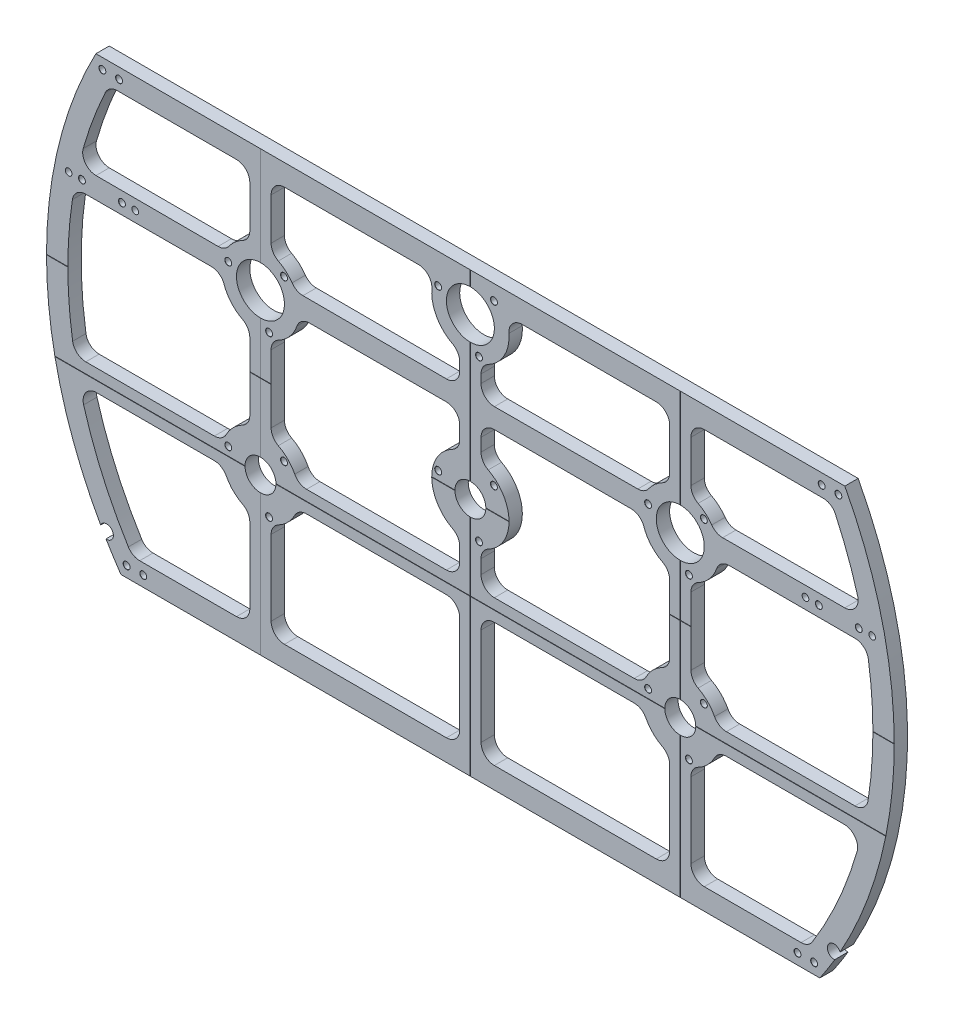
from build123d import *

# Parameters (mm, degrees)
BOSS_EXTRUDE1_DEPTH               = 12.7
SKETCH2_R                         = 3.175
CUT_EXTRUDE2_DEPTH                = 572.285470846
SKETCH5_R                         = 14.732
SKETCH5_R_2                       = 22.86
CUT_EXTRUDE3_DEPTH                = 572.285470846
CUT_EXTRUDE1_DEPTH                = 465.243631728
CIRPATTERN1_COUNT                 = 2
CIRPATTERN1_ANGLE                 = 90
F_1_4_20_TAPPED_HOLE1_D           = 6.35
F_1_4_20_TAPPED_HOLE1_CSINK_D     = 6.604
F_1_4_20_TAPPED_HOLE1_CSINK_ANGLE = 90
CUT_EXTRUDE4_DEPTH                = 465.243631728
CUT_EXTRUDE4_DEPTH_BACK           = 465.243631728
CUT_EXTRUDE5_DEPTH                = 465.243631728
CUT_EXTRUDE5_DEPTH_BACK           = 465.243631728
CUT_EXTRUDE6_DEPTH                = 465.243631728
FILLET1_R                         = 12.7


with BuildPart() as part:
    # Sketch → Boss-Extrude1 (new body)
    with BuildSketch(Plane.XY):
        with BuildLine():
            ThreePointArc((352.277102438, -197.493652299), (0, 403.86), (-352.277102438, -197.493652299))
            ThreePointArc((-352.277102438, -197.493652299), (-340.95420147, -196.85), (-347.173071195, -206.334093733))
            ThreePointArc((-347.173071195, -206.334093733), (0, -403.86), (347.173071195, -206.334093733))
            ThreePointArc((347.173071195, -206.334093733), (340.95420147, -196.85), (352.277102438, -197.493652299))
        make_face()
    extrude(amount=-BOSS_EXTRUDE1_DEPTH)

    # Sketch2 → Cut-Extrude2 (cut, through all)
    with BuildSketch(Plane.XY):
        with Locations((319.291621474, 78.613)):
            Circle(SKETCH2_R)
        with Locations((382.791621474, 78.613)):
            Circle(SKETCH2_R)
        with Locations(Location((-382.791621474, 78.613, 0), (0, 0, 180))):
            Circle(SKETCH2_R)
        with Locations(Location((-319.291621474, 78.613, 0), (0, 0, 180))):
            Circle(SKETCH2_R)
    extrude(amount=-CUT_EXTRUDE2_DEPTH, mode=Mode.SUBTRACT)

    # Sketch5 → Cut-Extrude3 (cut, through all)
    with BuildSketch(Plane(origin=(0, 0, -12.7), x_dir=(-1, 0, 0), z_dir=(0, 0, -1))):
        with Locations((-200, -80)):
            Circle(SKETCH5_R)
        with Locations((200, -80)):
            Circle(SKETCH5_R)
        with Locations((0, 152.4)):
            Circle(SKETCH5_R_2)
        Circle(SKETCH5_R)
        with Locations((-200, 72.4)):
            Circle(SKETCH5_R_2)
        with Locations((200, 72.4)):
            Circle(SKETCH5_R_2)
        with BuildLine():
            Line((356.78411778, 189.23), (-356.78411778, 189.23))
            ThreePointArc((-356.78411778, 189.23), (0, 403.86), (356.78411778, 189.23))
        make_face()
        with BuildLine():
            Line((332.93383667, -228.6), (-332.93383667, -228.6))
            ThreePointArc((-332.93383667, -228.6), (0, -403.86), (332.93383667, -228.6))
        make_face()
    extrude(amount=-CUT_EXTRUDE3_DEPTH, mode=Mode.SUBTRACT)

    # Sketch1 → Cut-Extrude1 (cut, symmetric)
    with BuildSketch(Plane(origin=(0, 0, 0), x_dir=(1, 0, 0), z_dir=(0, 1, 0))):
        Polygon((0.1905, 0), (-0.1905, 0), (0, 0.1905), align=None)
    cut_extrude1 = extrude(amount=CUT_EXTRUDE1_DEPTH, both=True, mode=Mode.SUBTRACT)

    # CirPattern1: Cut-Extrude1 ×2 about axis
    cirpattern1_axis = Axis((0, 0, -13.335), (0, 0, 1))
    for i in range(1, CIRPATTERN1_COUNT):
        add(cut_extrude1.rotate(cirpattern1_axis, i * CIRPATTERN1_ANGLE / (CIRPATTERN1_COUNT - 1)), mode=Mode.SUBTRACT)

    # 1_4-20 Tapped Hole1 (through all)
    with Locations(Plane.XY):
        with Locations((331.991621474, 78.613), (370.091621474, 78.613), (-370.091621474, 78.613), (-331.991621474, 78.613), (327.54183916, -218.44), (-327.54183916, -218.44), (350.618917202, 179.07), (222.450640303, 94.850640303), (-177.549359697, 94.850640303), (-191.782495318, 41.731855015), (-230.668144985, 80.617504682), (208.217504682, 41.731855015), (169.331855015, 80.617504682), (22.450640303, 174.850640303), (8.217504682, 121.731855015), (-30.668144985, 160.617504682), (334.743917202, 179.07), (311.66683916, -218.44), (-311.66683916, -218.44), (-350.618917202, 179.07), (-334.743917202, 179.07), (-177.549359697, -57.549359697), (22.450640303, 22.450640303), (222.450640303, -57.549359697), (8.217504682, -30.668144985), (-30.668144985, 8.217504682), (-191.782495318, -110.668144985), (-230.668144985, -71.782495318), (208.217504682, -110.668144985), (169.331855015, -71.782495318)):
            CounterSinkHole(F_1_4_20_TAPPED_HOLE1_D / 2, F_1_4_20_TAPPED_HOLE1_CSINK_D / 2, counter_sink_angle=F_1_4_20_TAPPED_HOLE1_CSINK_ANGLE)

    # Sketch6 → Cut-Extrude4 (cut, two sides)
    with BuildSketch(Plane(origin=(0, 0, 0), x_dir=(1, 0, 0), z_dir=(0, 1, 0))) as cut_extrude4_sk:
        Polygon((199.8095, 0), (200, 0.1905), (200.1905, 0), align=None)
        Polygon((-200.1905, 0), (-199.8095, 0), (-200, 0.1905), align=None)
    extrude(amount=CUT_EXTRUDE4_DEPTH, mode=Mode.SUBTRACT)
    extrude(cut_extrude4_sk.sketch, amount=-CUT_EXTRUDE4_DEPTH_BACK, mode=Mode.SUBTRACT)

    # Sketch7 → Cut-Extrude5 (cut, two sides)
    with BuildSketch(Plane(origin=(0, 0, 0), x_dir=(0, 0, -1), z_dir=(1, 0, 0))) as cut_extrude5_sk:
        Polygon((0, -80.1905), (0, -79.8095), (0.1905, -80), align=None)
    extrude(amount=CUT_EXTRUDE5_DEPTH, mode=Mode.SUBTRACT)
    extrude(cut_extrude5_sk.sketch, amount=-CUT_EXTRUDE5_DEPTH_BACK, mode=Mode.SUBTRACT)

    # Sketch8 → Cut-Extrude6 (cut, through all)
    with BuildSketch(Plane.XY):
        with BuildLine():
            Line((189.84, 168.91), (189.84, 107.800894057))
            ThreePointArc((189.84, 107.800894057), (176.187928288, 100.496870658), (166.744209752, 88.227233333))
            Line((166.744209752, 88.227233333), (10.16, 87.821520418))
            Line((10.16, 87.821520418), (10.16, 116.999105943))
            ThreePointArc((10.16, 116.999105943), (33.72985943, 137.609953252), (32.922162748, 168.91))
            Line((32.922162748, 168.91), (189.84, 168.91))
        make_face()
        with BuildLine():
            Line((210.16, 168.91), (210.16, 107.800894057))
            ThreePointArc((210.16, 107.800894057), (223.739192456, 100.558473707), (233.173326908, 88.399352545))
            Line((233.173326908, 88.399352545), (373.127649772, 88.761977081))
            ThreePointArc((373.127649772, 88.761977081), (360.966876175, 129.637363074), (344.343351177, 168.91))
            Line((344.343351177, 168.91), (210.16, 168.91))
        make_face()
        with BuildLine():
            Line((10.16, -208.28), (189.84, -208.28))
            Line((189.84, -208.28), (189.84, -115.400894057))
            ThreePointArc((189.84, -115.400894057), (173.957257249, -106.042742751), (164.599105943, -90.16))
            Line((164.599105943, -90.16), (10.16, -90.16))
            Line((10.16, -90.16), (10.16, -208.28))
        make_face()
        with BuildLine():
            Line((210.16, -208.28), (322.059580202, -208.28))
            ThreePointArc((322.059580202, -208.28), (352.410088881, -151.360697854), (372.79230947, -90.16))
            Line((372.79230947, -90.16), (235.400894057, -90.16))
            ThreePointArc((235.400894057, -90.16), (226.042742751, -106.042742751), (210.16, -115.400894057))
            Line((210.16, -115.400894057), (210.16, -208.28))
        make_face()
        with BuildLine():
            Line((-10.16, -35.400894057), (-10.16, -69.84))
            Line((-10.16, -69.84), (-164.599105943, -69.84))
            ThreePointArc((-164.599105943, -69.84), (-173.957257249, -53.957257249), (-189.84, -44.599105943))
            Line((-189.84, -44.599105943), (-189.84, 36.999105943))
            ThreePointArc((-189.84, 36.999105943), (-171.729781638, 48.793991151), (-163.354541091, 68.717712488))
            Line((-163.354541091, 68.717712488), (-10.16, 68.907185943))
            Line((-10.16, 68.907185943), (-10.16, 35.400894057))
            ThreePointArc((-10.16, 35.400894057), (-36.83, 0), (-10.16, -35.400894057))
        make_face()
        with BuildLine():
            Line((10.16, 68.907185943), (10.16, 35.400894057))
            ThreePointArc((10.16, 35.400894057), (36.83, 0), (10.16, -35.400894057))
            Line((10.16, -35.400894057), (10.16, -69.84))
            Line((10.16, -69.84), (164.599105943, -69.84))
            ThreePointArc((164.599105943, -69.84), (173.957257249, -53.957257249), (189.84, -44.599105943))
            Line((189.84, -44.599105943), (189.84, 36.999105943))
            ThreePointArc((189.84, 36.999105943), (171.729781638, 48.793991151), (163.354541091, 68.717712488))
            Line((163.354541091, 68.717712488), (10.16, 68.907185943))
        make_face()
        with BuildLine():
            Line((-189.84, -115.400894057), (-189.84, -208.28))
            Line((-189.84, -208.28), (-10.16, -208.28))
            Line((-10.16, -208.28), (-10.16, -90.16))
            Line((-10.16, -90.16), (-164.599105943, -90.16))
            ThreePointArc((-164.599105943, -90.16), (-173.957257249, -106.042742751), (-189.84, -115.400894057))
        make_face()
        with BuildLine():
            Line((-235.400894057, -90.16), (-372.79230947, -90.16))
            ThreePointArc((-372.79230947, -90.16), (-352.410088881, -151.360697854), (-322.059580202, -208.28))
            Line((-322.059580202, -208.28), (-210.16, -208.28))
            Line((-210.16, -208.28), (-210.16, -115.400894057))
            ThreePointArc((-210.16, -115.400894057), (-226.042742751, -106.042742751), (-235.400894057, -90.16))
        make_face()
        with BuildLine():
            Line((236.636238185, 68.627076515), (377.381926423, 68.453))
            ThreePointArc((377.381926423, 68.453), (383.539351958, -0.705052737), (377.127705161, -69.84))
            Line((377.127705161, -69.84), (235.400894057, -69.84))
            ThreePointArc((235.400894057, -69.84), (226.042742751, -53.957257249), (210.16, -44.599105943))
            Line((210.16, -44.599105943), (210.16, 36.999105943))
            ThreePointArc((210.16, 36.999105943), (228.241000473, 48.759044175), (236.636238185, 68.627076515))
        make_face()
        with BuildLine():
            Line((-235.400894057, -69.84), (-377.127705161, -69.84))
            ThreePointArc((-377.127705161, -69.84), (-383.539351958, -0.705052737), (-377.381926423, 68.453))
            Line((-377.381926423, 68.453), (-236.636238185, 68.627076515))
            ThreePointArc((-236.636238185, 68.627076515), (-228.241000473, 48.759044175), (-210.16, 36.999105943))
            Line((-210.16, 36.999105943), (-210.16, -44.599105943))
            ThreePointArc((-210.16, -44.599105943), (-226.042742751, -53.957257249), (-235.400894057, -69.84))
        make_face()
        with BuildLine():
            Line((-233.173326908, 88.399352545), (-373.127649772, 88.761977081))
            ThreePointArc((-373.127649772, 88.761977081), (-360.966876175, 129.637363074), (-344.343351177, 168.91))
            Line((-344.343351177, 168.91), (-210.16, 168.91))
            Line((-210.16, 168.91), (-210.16, 107.800894057))
            ThreePointArc((-210.16, 107.800894057), (-223.739192456, 100.558473707), (-233.173326908, 88.399352545))
        make_face()
        with BuildLine():
            Line((-10.16, 87.821520418), (-166.744209752, 88.227233333))
            ThreePointArc((-166.744209752, 88.227233333), (-176.187928288, 100.496870658), (-189.84, 107.800894057))
            Line((-189.84, 107.800894057), (-189.84, 168.91))
            Line((-189.84, 168.91), (-32.922162748, 168.91))
            ThreePointArc((-32.922162748, 168.91), (-33.72985943, 137.609953252), (-10.16, 116.999105943))
            Line((-10.16, 116.999105943), (-10.16, 87.821520418))
        make_face()
    extrude(amount=-CUT_EXTRUDE6_DEPTH, mode=Mode.SUBTRACT)

    # Fillet1
    fillet1_edges = [part.edges().sort_by_distance(p)[0] for p in [
        (10.16, -35.400894057, -6.35),
        (189.84, 36.999105943, -6.35),
        (10.16, 35.400894057, -6.35),
        (10.16, 68.907185943, -6.35),
        (163.354541091, 68.717712488, -6.35),
        (189.84, -44.599105943, -6.35),
        (164.599105943, -69.84, -6.35),
        (10.16, -69.84, -6.35),
        (-322.059580202, -208.28, -6.35),
        (-372.79230947, -90.16, -6.35),
        (-235.400894057, -90.16, -6.35),
        (-210.16, -115.400894057, -6.35),
        (-210.16, -208.28, -6.35),
        (189.84, 107.800894057, -6.35),
        (166.744209752, 88.227233333, -6.35),
        (10.16, 87.821520418, -6.35),
        (10.16, 116.999105943, -6.35),
        (32.922162748, 168.91, -6.35),
        (189.84, 168.91, -6.35),
        (377.381926423, 68.453, -6.35),
        (210.16, -44.599105943, -6.35),
        (377.127705161, -69.84, -6.35),
        (235.400894057, -69.84, -6.35),
        (210.16, 36.999105943, -6.35),
        (236.636238185, 68.627076515, -6.35),
        (344.343351177, 168.91, -6.35),
        (373.127649772, 88.761977081, -6.35),
        (233.173326908, 88.399352545, -6.35),
        (210.16, 107.800894057, -6.35),
        (210.16, 168.91, -6.35),
        (372.79230947, -90.16, -6.35),
        (322.059580202, -208.28, -6.35),
        (210.16, -208.28, -6.35),
        (210.16, -115.400894057, -6.35),
        (235.400894057, -90.16, -6.35),
        (189.84, -115.400894057, -6.35),
        (189.84, -208.28, -6.35),
        (10.16, -208.28, -6.35),
        (10.16, -90.16, -6.35),
        (164.599105943, -90.16, -6.35),
        (-377.127705161, -69.84, -6.35),
        (-210.16, 36.999105943, -6.35),
        (-377.381926423, 68.453, -6.35),
        (-236.636238185, 68.627076515, -6.35),
        (-210.16, -44.599105943, -6.35),
        (-235.400894057, -69.84, -6.35),
        (-189.84, 107.800894057, -6.35),
        (-189.84, 168.91, -6.35),
        (-32.922162748, 168.91, -6.35),
        (-10.16, 116.999105943, -6.35),
        (-10.16, 87.821520418, -6.35),
        (-166.744209752, 88.227233333, -6.35),
        (-210.16, 168.91, -6.35),
        (-210.16, 107.800894057, -6.35),
        (-233.173326908, 88.399352545, -6.35),
        (-373.127649772, 88.761977081, -6.35),
        (-344.343351177, 168.91, -6.35),
        (-10.16, 35.400894057, -6.35),
        (-189.84, -44.599105943, -6.35),
        (-10.16, -35.400894057, -6.35),
        (-10.16, -69.84, -6.35),
        (-164.599105943, -69.84, -6.35),
        (-189.84, 36.999105943, -6.35),
        (-163.354541091, 68.717712488, -6.35),
        (-10.16, 68.907185943, -6.35),
        (-189.84, -115.400894057, -6.35),
        (-164.599105943, -90.16, -6.35),
        (-10.16, -90.16, -6.35),
        (-10.16, -208.28, -6.35),
        (-189.84, -208.28, -6.35),
    ]]
    fillet(fillet1_edges, radius=FILLET1_R)


solid = part.part
